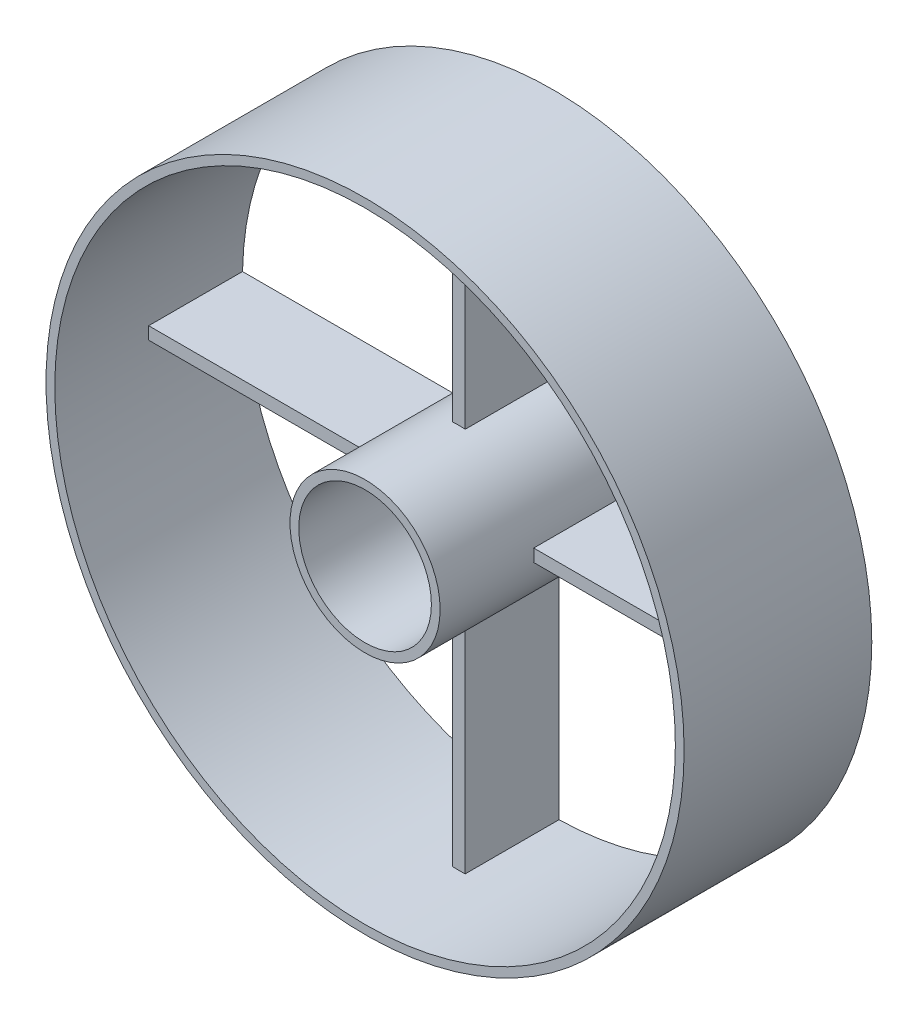
from build123d import *

# Parameters (mm, degrees)
SKETCH1_R                  = 25.5
SKETCH1_R_2                = 24.8
EXTRUDE_THIN1_DEPTH        = 7.5
EXTRUDE_THIN1_DEPTH_BACK   = 7.5
SKETCH1_R_3                = 6
SKETCH1_R_4                = 5.3
EXTRUDE_THIN1_2_DEPTH      = 7.5
EXTRUDE_THIN1_2_DEPTH_BACK = 7.5
EXTRUDE1_DEPTH             = 7.5


with BuildPart() as part:
    # Sketch1 → Extrude-Thin1 (new body, two sides)
    with BuildSketch(Plane.XY) as extrude_thin1_sk:
        Circle(SKETCH1_R)
        Circle(SKETCH1_R_2, mode=Mode.SUBTRACT)
    extrude(amount=EXTRUDE_THIN1_DEPTH)
    extrude(extrude_thin1_sk.sketch, amount=-EXTRUDE_THIN1_DEPTH_BACK)



with BuildPart() as body_2:
    # Sketch1 → Extrude-Thin1 2 (new body, two sides)
    with BuildSketch(Plane.XY) as extrude_thin1_2_sk:
        Circle(SKETCH1_R_3)
        Circle(SKETCH1_R_4, mode=Mode.SUBTRACT)
    extrude(amount=EXTRUDE_THIN1_2_DEPTH)
    extrude(extrude_thin1_2_sk.sketch, amount=-EXTRUDE_THIN1_2_DEPTH_BACK)


with BuildPart() as part_1:
    add(part.part)

    add(body_2.part)  # Extrude1 merges body 2
    # Sketch2 → Extrude1 (add)
    with BuildSketch(Plane.XY):
        with BuildLine():
            Line((-0.5, 24.794959165), (-0.5, 5.979130372))
            ThreePointArc((-0.5, 5.979130372), (0, 6), (0.5, 5.979130372))
            Line((0.5, 5.979130372), (0.5, 24.794959165))
            ThreePointArc((0.5, 24.794959165), (0, 24.8), (-0.5, 24.794959165))
        make_face()
        with BuildLine():
            Line((-24.794959165, 0.5), (-5.979130372, 0.5))
            ThreePointArc((-5.979130372, 0.5), (-6, 0), (-5.979130372, -0.5))
            Line((-5.979130372, -0.5), (-24.794959165, -0.5))
            ThreePointArc((-24.794959165, -0.5), (-24.8, 0), (-24.794959165, 0.5))
        make_face()
        with BuildLine():
            Line((-0.5, -24.794959165), (-0.5, -5.979130372))
            ThreePointArc((-0.5, -5.979130372), (0, -6), (0.5, -5.979130372))
            Line((0.5, -5.979130372), (0.5, -24.794959165))
            ThreePointArc((0.5, -24.794959165), (0, -24.8), (-0.5, -24.794959165))
        make_face()
        with BuildLine():
            Line((5.979130372, 0.5), (24.794959165, 0.5))
            ThreePointArc((24.794959165, 0.5), (24.8, 0), (24.794959165, -0.5))
            Line((24.794959165, -0.5), (5.979130372, -0.5))
            ThreePointArc((5.979130372, -0.5), (6, 0), (5.979130372, 0.5))
        make_face()
    extrude(amount=-EXTRUDE1_DEPTH)


solid = part_1.part
